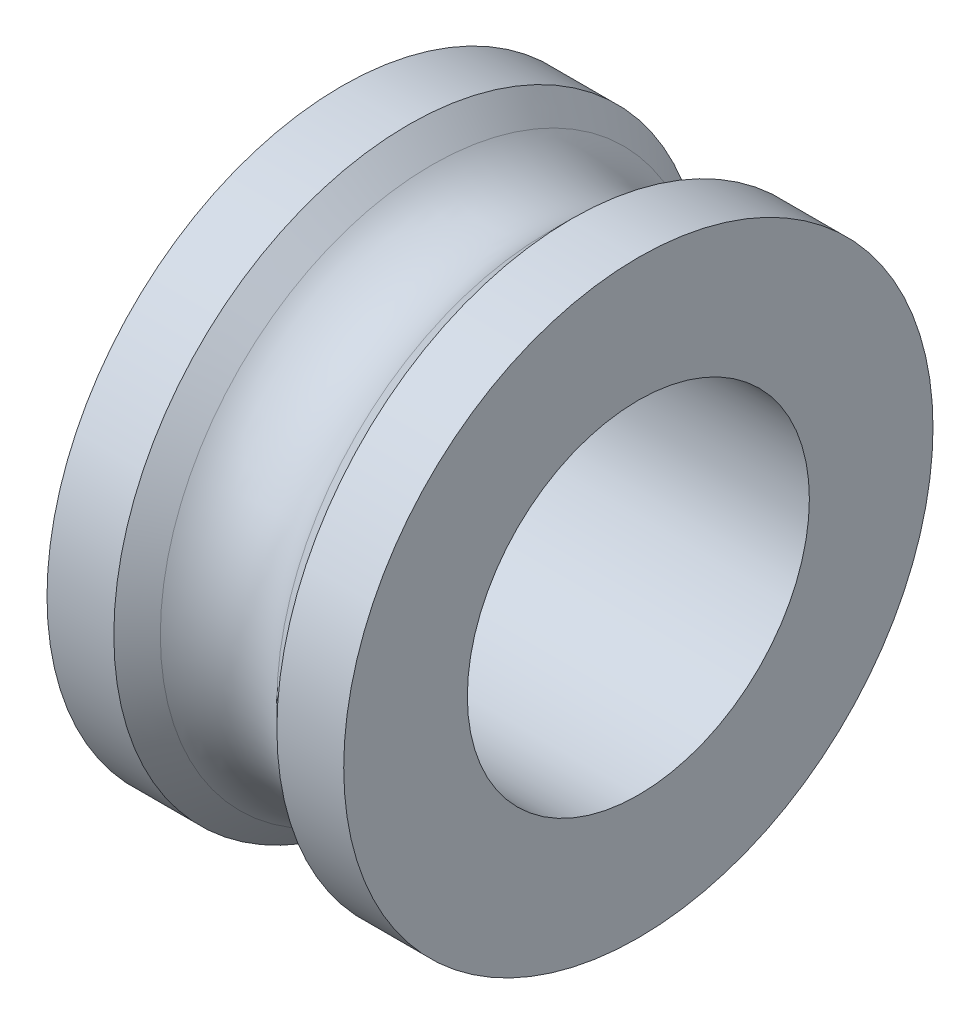
from build123d import *


with BuildPart() as part:
    # Skizze1 → Rotation1 (revolve)
    with BuildSketch(Plane.XY):
        with BuildLine():
            Line((-1.8, 2.075), (1.8, 2.075))
            Line((1.8, 2.075), (1.8, 3.575))
            Line((1.8, 3.575), (0.989213562, 3.575))
            Line((0.989213562, 3.575), (0.707106781, 3.292893219))
            ThreePointArc((0.707106781, 3.292893219), (0, 3), (-0.707106781, 3.292893219))
            Line((-0.707106781, 3.292893219), (-0.989213562, 3.575))
            Line((-0.989213562, 3.575), (-1.8, 3.575))
            Line((-1.8, 3.575), (-1.8, 2.075))
        make_face()
    revolve(axis=Axis((12.155941494, 0, 0), (-1, 0, 0)))


solid = part.part
